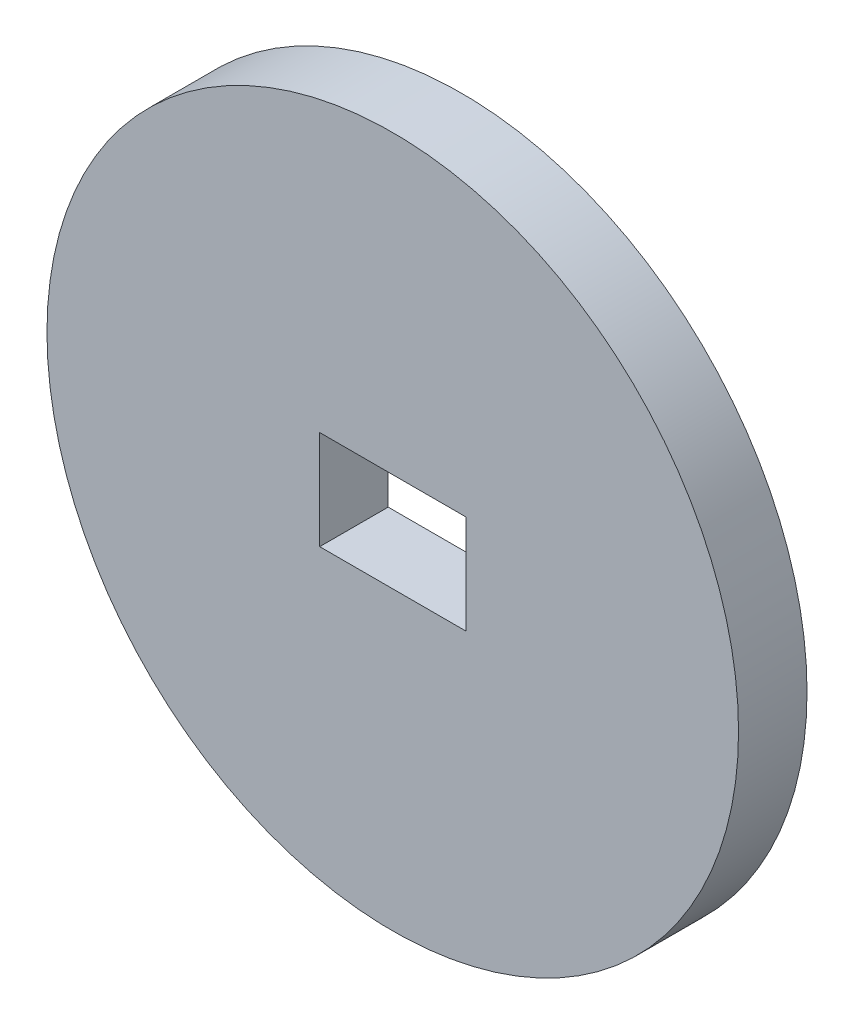
from build123d import *

# Parameters (mm, degrees)
SKETCH1_R           = 12.875
BOSS_EXTRUDE1_DEPTH = 2.55
SKETCH2_W           = 5.44
SKETCH2_H           = 3.68
CUT_EXTRUDE1_DEPTH  = 2.55


with BuildPart() as part:
    # Sketch1 → Boss-Extrude1 (new body)
    with BuildSketch(Plane.XY):
        Circle(SKETCH1_R)
    extrude(amount=BOSS_EXTRUDE1_DEPTH)

    # Sketch2 → Cut-Extrude1 (cut)
    with BuildSketch(Plane.XY):
        Rectangle(SKETCH2_W, SKETCH2_H)
    extrude(amount=CUT_EXTRUDE1_DEPTH, mode=Mode.SUBTRACT)


solid = part.part
